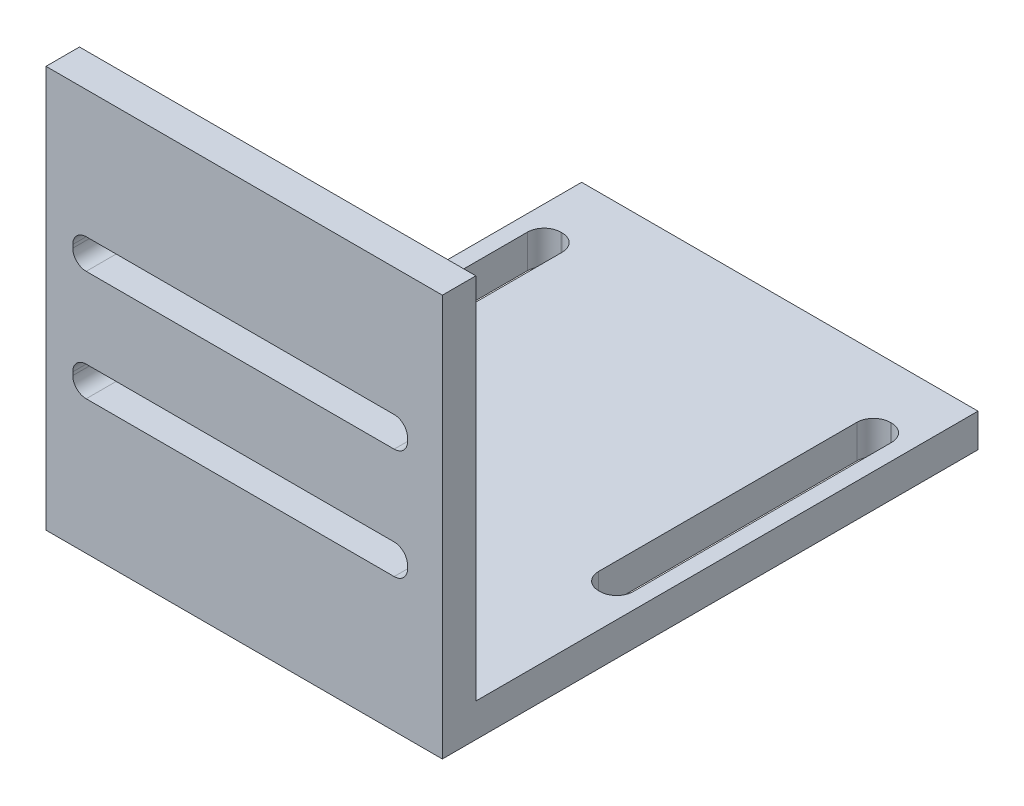
from build123d import *

# Parameters (mm, degrees)
SKETCH1_W           = 37.592
SKETCH1_H           = 50.8
BOSS_EXTRUDE1_DEPTH = 3.175
SKETCH2_W           = 37.592
SKETCH2_H           = 3.175
BOSS_EXTRUDE2_DEPTH = 34.925
CUT_EXTRUDE1_REACH  = 52.8
CUT_EXTRUDE2_REACH  = 40.1


with BuildPart() as part:
    # Sketch1 → Boss-Extrude1 (new body)
    with BuildSketch(Plane(origin=(0, 0, 0), x_dir=(1, 0, 0), z_dir=(0, 1, 0))):
        Rectangle(SKETCH1_W, SKETCH1_H)
    extrude(amount=BOSS_EXTRUDE1_DEPTH)

    # Sketch2 → Boss-Extrude2 (add)
    with BuildSketch(Plane(origin=(0, 3.175, 0), x_dir=(1, 0, 0), z_dir=(0, 1, 0))):
        with Locations((0, -23.8125)):
            Rectangle(SKETCH2_W, SKETCH2_H)
    extrude(amount=BOSS_EXTRUDE2_DEPTH)

    # Sketch3 → Cut-Extrude1 (cut, up to next)
    with BuildSketch(Plane.XY.offset(25.4), mode=Mode.PRIVATE) as cut_extrude1_sk1:
        with BuildLine():
            Line((14.224, 12.7), (-14.986, 12.7))
            ThreePointArc((-14.986, 12.7), (-15.884025612, 13.071974388), (-16.256, 13.97))
            Line((-16.256, 13.97), (-16.256, 14.2748))
            ThreePointArc((-16.256, 14.2748), (-15.884025612, 15.172825612), (-14.986, 15.5448))
            Line((-14.986, 15.5448), (14.224, 15.5448))
            ThreePointArc((14.224, 15.5448), (15.122025612, 15.172825612), (15.494, 14.2748))
            Line((15.494, 14.2748), (15.494, 13.97))
            ThreePointArc((15.494, 13.97), (15.122025612, 13.071974388), (14.224, 12.7))
        make_face()
    cut_extrude1_tool1 = extrude(cut_extrude1_sk1.sketch, amount=-CUT_EXTRUDE1_REACH, mode=Mode.PRIVATE) & part.part
    add(cut_extrude1_tool1.solids().sort_by_distance((-0.381, 14.1224, 25.4))[0], mode=Mode.SUBTRACT)
    # Sketch3 → Cut-Extrude1 (cut, up to next)
    with BuildSketch(Plane.XY.offset(25.4), mode=Mode.PRIVATE) as cut_extrude1_sk2:
        with BuildLine():
            Line((-14.986, 23.1648), (14.224, 23.1648))
            ThreePointArc((14.224, 23.1648), (15.122025612, 23.536774388), (15.494, 24.4348))
            Line((15.494, 24.4348), (15.494, 24.7396))
            ThreePointArc((15.494, 24.7396), (15.122025612, 25.637625612), (14.224, 26.0096))
            Line((14.224, 26.0096), (-14.986, 26.0096))
            ThreePointArc((-14.986, 26.0096), (-15.884025612, 25.637625612), (-16.256, 24.7396))
            Line((-16.256, 24.7396), (-16.256, 24.4348))
            ThreePointArc((-16.256, 24.4348), (-15.884025612, 23.536774388), (-14.986, 23.1648))
        make_face()
    cut_extrude1_tool2 = extrude(cut_extrude1_sk2.sketch, amount=-CUT_EXTRUDE1_REACH, mode=Mode.PRIVATE) & part.part
    add(cut_extrude1_tool2.solids().sort_by_distance((-0.381, 24.5872, 25.4))[0], mode=Mode.SUBTRACT)

    # Sketch4 → Cut-Extrude2 (cut, up to next)
    with BuildSketch(Plane.XZ, mode=Mode.PRIVATE) as cut_extrude2_sk1:
        with BuildLine():
            Line((-15.5575, -20.32), (-15.6845, -20.32))
            ThreePointArc((-15.6845, -20.32), (-16.807032015, -19.855032015), (-17.272, -18.7325))
            Line((-17.272, -18.7325), (-17.272, 5.759956222))
            ThreePointArc((-17.272, 5.759956222), (-16.807032015, 6.882488237), (-15.6845, 7.347456222))
            Line((-15.6845, 7.347456222), (-15.5575, 7.347456222))
            ThreePointArc((-15.5575, 7.347456222), (-14.434967985, 6.882488237), (-13.97, 5.759956222))
            Line((-13.97, 5.759956222), (-13.97, -18.7325))
            ThreePointArc((-13.97, -18.7325), (-14.434967985, -19.855032015), (-15.5575, -20.32))
        make_face()
    cut_extrude2_tool1 = extrude(cut_extrude2_sk1.sketch, amount=-CUT_EXTRUDE2_REACH, mode=Mode.PRIVATE) & part.part
    add(cut_extrude2_tool1.solids().sort_by_distance((-15.621, 0, -6.486272))[0], mode=Mode.SUBTRACT)
    # Sketch4 → Cut-Extrude2 (cut, up to next)
    with BuildSketch(Plane.XZ, mode=Mode.PRIVATE) as cut_extrude2_sk2:
        with BuildLine():
            Line((15.6845, -20.32), (15.5575, -20.32))
            ThreePointArc((15.5575, -20.32), (14.434967985, -19.855032015), (13.97, -18.7325))
            Line((13.97, -18.7325), (13.97, 5.759956222))
            ThreePointArc((13.97, 5.759956222), (14.434967985, 6.882488237), (15.5575, 7.347456222))
            Line((15.5575, 7.347456222), (15.6845, 7.347456222))
            ThreePointArc((15.6845, 7.347456222), (16.807032015, 6.882488237), (17.272, 5.759956222))
            Line((17.272, 5.759956222), (17.272, -18.7325))
            ThreePointArc((17.272, -18.7325), (16.807032015, -19.855032015), (15.6845, -20.32))
        make_face()
    cut_extrude2_tool2 = extrude(cut_extrude2_sk2.sketch, amount=-CUT_EXTRUDE2_REACH, mode=Mode.PRIVATE) & part.part
    add(cut_extrude2_tool2.solids().sort_by_distance((15.621, 0, -6.486272))[0], mode=Mode.SUBTRACT)


solid = part.part
